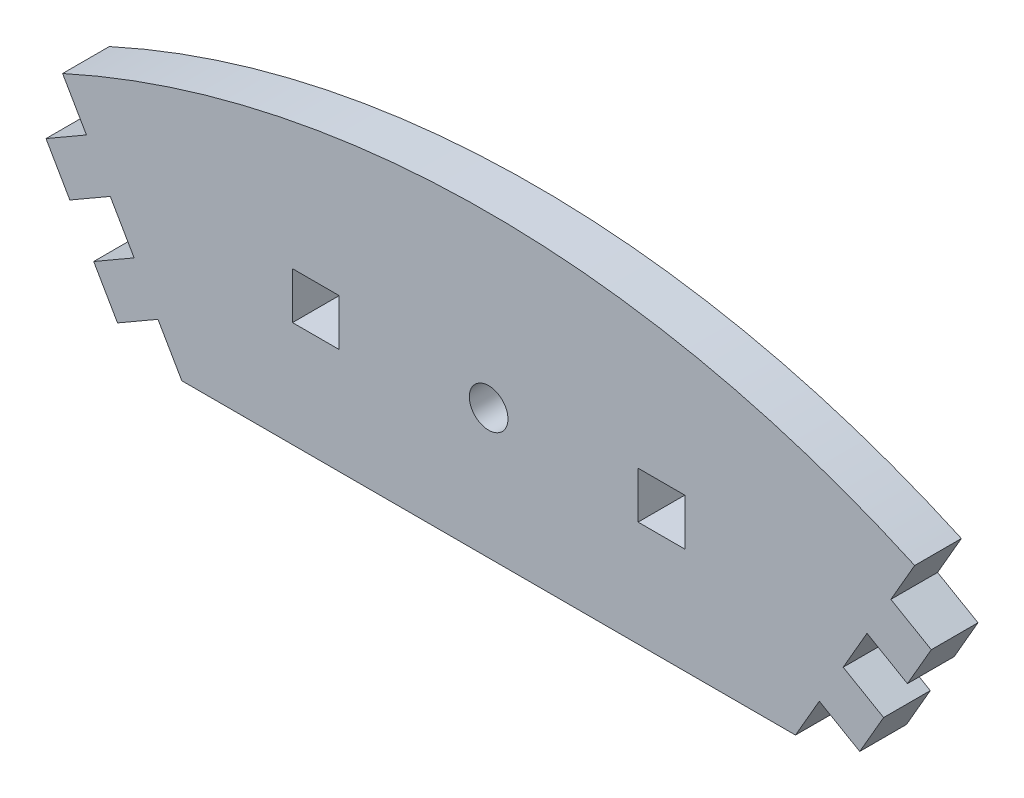
from build123d import *

# Parameters (mm, degrees)
BOSS_EXTRUDE1_DEPTH = 5
SKETCH2_R           = 2.0675
SKETCH2_W           = 5
SKETCH2_H           = 5
CUT_EXTRUDE1_DEPTH  = 6


with BuildPart() as part:
    # Sketch1 → Boss-Extrude1 (new body)
    with BuildSketch(Plane.XY):
        with BuildLine():
            Line((-32.85, 77.986683936), (32.85, 77.986683936))
            Line((32.85, 77.986683936), (35.403, 82.408609648))
            Line((35.403, 82.408609648), (39.733127019, 79.908609648))
            Line((39.733127019, 79.908609648), (42.286127019, 84.330535359))
            Line((42.286127019, 84.330535359), (37.956, 86.830535359))
            Line((37.956, 86.830535359), (40.509, 91.252461071))
            Line((40.509, 91.252461071), (44.839127019, 88.752461071))
            Line((44.839127019, 88.752461071), (47.392127019, 93.174386783))
            Line((47.392127019, 93.174386783), (43.062, 95.674386783))
            Line((43.062, 95.674386783), (45.615, 100.096312495))
            ThreePointArc((45.615, 100.096312495), (0, 110), (-45.615, 100.096312495))
            Line((-45.615, 100.096312495), (-43.062, 95.674386783))
            Line((-43.062, 95.674386783), (-47.392127019, 93.174386783))
            Line((-47.392127019, 93.174386783), (-44.839127019, 88.752461071))
            Line((-44.839127019, 88.752461071), (-40.509, 91.252461071))
            Line((-40.509, 91.252461071), (-37.956, 86.830535359))
            Line((-37.956, 86.830535359), (-42.286127019, 84.330535359))
            Line((-42.286127019, 84.330535359), (-39.733127019, 79.908609648))
            Line((-39.733127019, 79.908609648), (-35.403, 82.408609648))
            Line((-35.403, 82.408609648), (-32.85, 77.986683936))
        make_face()
    extrude(amount=BOSS_EXTRUDE1_DEPTH)

    # Sketch2 → Cut-Extrude1 (cut, through all)
    with BuildSketch(Plane.XY.offset(5)):
        with Locations((0, 91.897414387)):
            Circle(SKETCH2_R)
        with Locations((18.5, 91.807821113)):
            Rectangle(SKETCH2_W, SKETCH2_H)
        with Locations((-18.5, 91.807821113)):
            Rectangle(SKETCH2_W, SKETCH2_H)
    extrude(amount=-CUT_EXTRUDE1_DEPTH, mode=Mode.SUBTRACT)


solid = part.part
